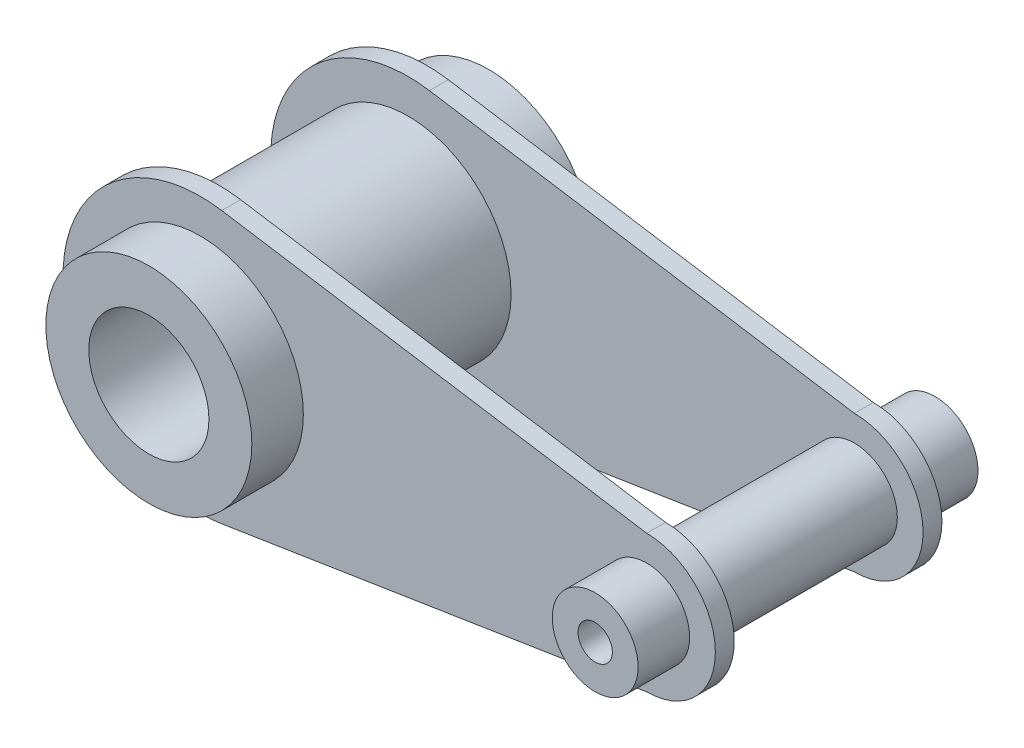
from build123d import *

# Parameters (mm, degrees)
BOSS_EXTRUDE1_DEPTH = 5.5
SKETCH2_R           = 30
SKETCH2_R_2         = 17.5
SKETCH2_R_3         = 12.5
SKETCH2_R_4         = 5
BOSS_EXTRUDE2_DEPTH = 99
SKETCH3_R           = 17.5
SKETCH3_R_2         = 5
CUT_EXTRUDE1_DEPTH  = 99
SKETCH4_R           = 5
CUT_EXTRUDE2_DEPTH  = 99
SKETCH5_R           = 17.5
CUT_EXTRUDE3_DEPTH  = 99


with BuildPart() as part:
    # Sketch1 → Boss-Extrude1 (new body)
    with BuildSketch(Plane.XY):
        with BuildLine():
            Line((6.228918342, 39.512030779), (130, 20))
            ThreePointArc((130, 20), (150, 0), (130, -20))
            Line((130, -20), (6.228918342, -39.512030779))
            ThreePointArc((6.228918342, -39.512030779), (-40, 0), (6.228918342, 39.512030779))
        make_face()
    boss_extrude1 = extrude(amount=BOSS_EXTRUDE1_DEPTH)

    # Sketch2 → Boss-Extrude2 (add)
    with BuildSketch(Plane.XY.offset(20.5)):
        Circle(SKETCH2_R)
        Circle(SKETCH2_R_2, mode=Mode.SUBTRACT)
        with Locations((130, 0)):
            Circle(SKETCH2_R_3)
        with Locations((130, 0)):
            Circle(SKETCH2_R_4, mode=Mode.SUBTRACT)
    extrude(amount=-BOSS_EXTRUDE2_DEPTH)

    # Sketch3 → Cut-Extrude1 (cut)
    with BuildSketch(Plane.XY.offset(5.5)):
        Circle(SKETCH3_R)
        with Locations((130, 0)):
            Circle(SKETCH3_R_2)
    extrude(amount=-CUT_EXTRUDE1_DEPTH, mode=Mode.SUBTRACT)

    # Mirror5: Boss-Extrude1 across plane
    add(boss_extrude1.mirror(Plane.XY.offset(-27.5)))

    # Sketch4 → Cut-Extrude2 (cut)
    with BuildSketch(Plane(origin=(0, 0, -60.5), x_dir=(-1, 0, 0), z_dir=(0, 0, -1))):
        with Locations((-130, 0)):
            Circle(SKETCH4_R)
    extrude(amount=-CUT_EXTRUDE2_DEPTH, mode=Mode.SUBTRACT)

    # Sketch5 → Cut-Extrude3 (cut)
    with BuildSketch(Plane(origin=(0, 0, -60.5), x_dir=(-1, 0, 0), z_dir=(0, 0, -1))):
        Circle(SKETCH5_R)
    extrude(amount=-CUT_EXTRUDE3_DEPTH, mode=Mode.SUBTRACT)


solid = part.part
